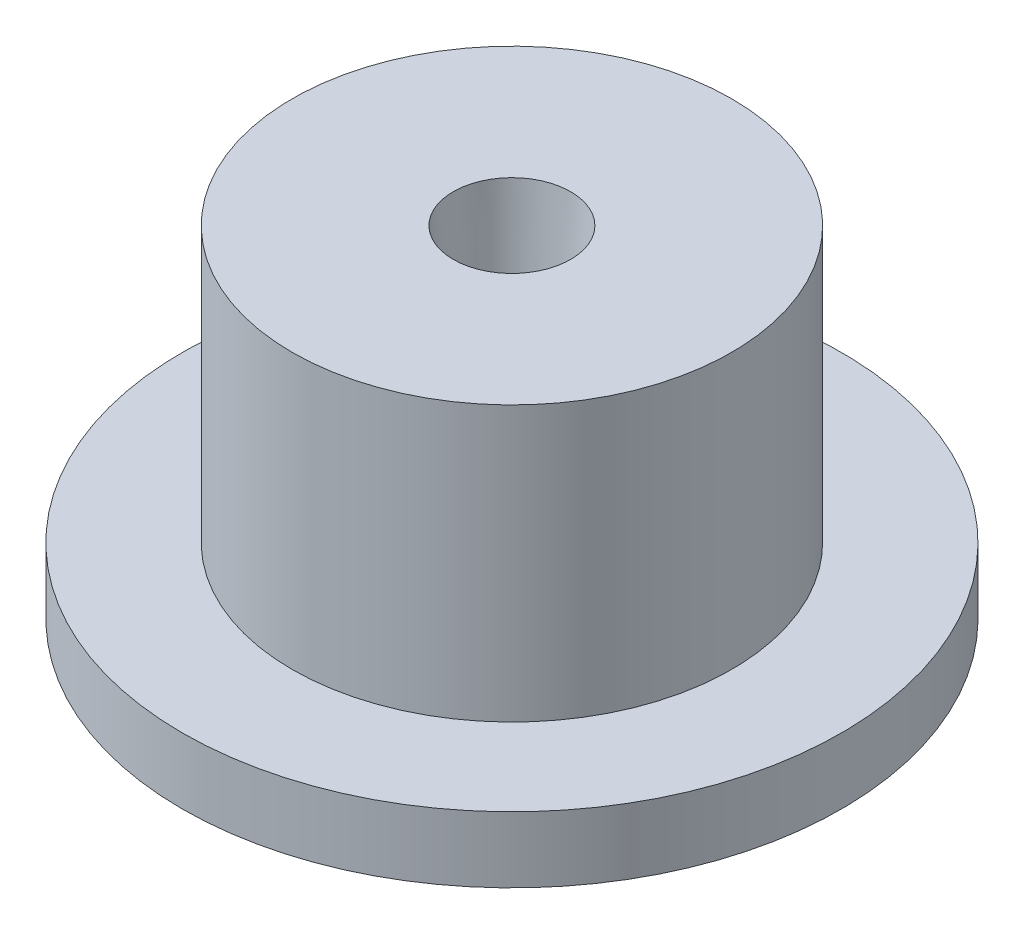
from build123d import *


with BuildPart() as part:
    # Sketch1 → Revolve1 (revolve)
    with BuildSketch(Plane.XY):
        Polygon((0.640403048, 0), (6, 0), (6, 1.2), (4, 1.2), (4, 6.2), (1.068740625, 6.2), align=None)
    revolve(axis=Axis((0, 20.666666667, 0), (0, -1, 0)))


solid = part.part
